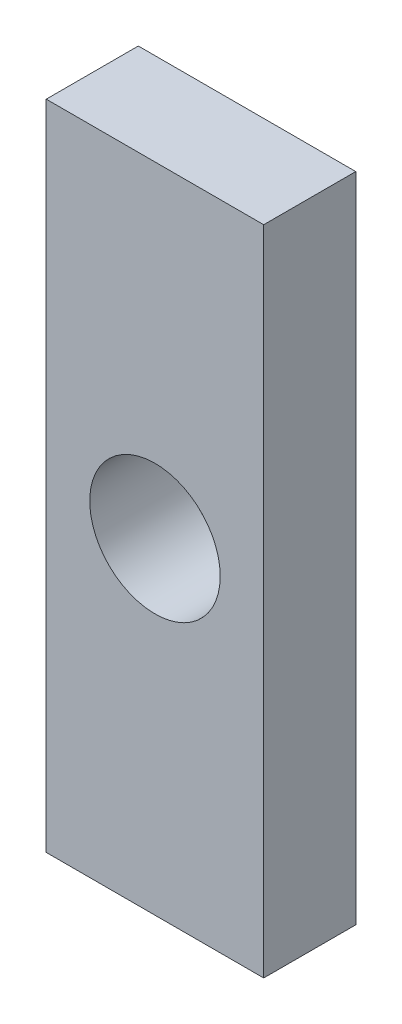
from build123d import *

# Parameters (mm, degrees)
SKETCH1_W           = 15
SKETCH1_H           = 45
BOSS_EXTRUDE1_DEPTH = 6.35
SKETCH3_R           = 4.5
CUT_EXTRUDE1_DEPTH  = 7.35


with BuildPart() as part:
    # Sketch1 → Boss-Extrude1 (new body)
    with BuildSketch(Plane.XY):
        with Locations((7.5, 22.5)):
            Rectangle(SKETCH1_W, SKETCH1_H)
    extrude(amount=BOSS_EXTRUDE1_DEPTH)

    # Sketch3 → Cut-Extrude1 (cut, through all)
    with BuildSketch(Plane.XY.offset(6.35)):
        with Locations((7.5, 22.5)):
            Circle(SKETCH3_R)
    extrude(amount=-CUT_EXTRUDE1_DEPTH, mode=Mode.SUBTRACT)


solid = part.part
